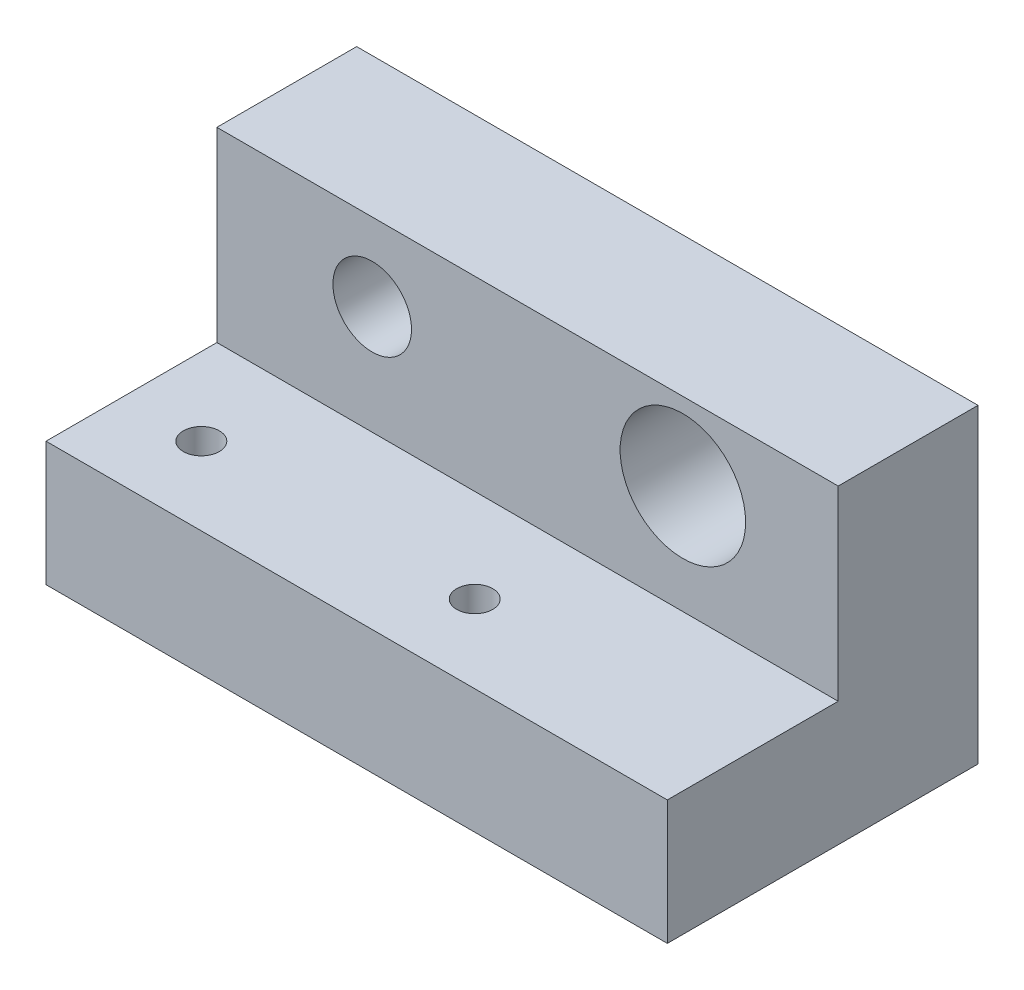
from build123d import *

# Parameters (mm, degrees)
BOSS_EXTRUDE1_DEPTH = 50.8
SKETCH4_R           = 1.4732
CUT_EXTRUDE1_DEPTH  = 11.16
SKETCH5_R           = 3.2131
SKETCH5_R_2         = 5.1308
CUT_EXTRUDE2_DEPTH  = 50.8


with BuildPart() as part:
    # Sketch3 → Boss-Extrude1 (new body)
    with BuildSketch(Plane(origin=(0, 0, 0), x_dir=(0, 0, -1), z_dir=(1, 0, 0))):
        Polygon((0, 0), (25.4, 0), (25.4, 25.4), (13.97, 25.4), (13.97, 10.16), (0, 10.16), align=None)
    extrude(amount=-BOSS_EXTRUDE1_DEPTH)

    # Sketch4 → Cut-Extrude1 (cut, through all)
    with BuildSketch(Plane(origin=(0, 10.16, 0), x_dir=(1, 0, 0), z_dir=(0, 1, 0))):
        with Locations((-44.45, 6.35)):
            Circle(SKETCH4_R)
        with Locations((-22.098, 6.35)):
            Circle(SKETCH4_R)
    extrude(amount=-CUT_EXTRUDE1_DEPTH, mode=Mode.SUBTRACT)

    # Sketch5 → Cut-Extrude2 (cut)
    with BuildSketch(Plane.XY.offset(-13.97)):
        with Locations((-38.1, 19.05)):
            Circle(SKETCH5_R)
        with Locations((-12.7, 19.05)):
            Circle(SKETCH5_R_2)
    extrude(amount=-CUT_EXTRUDE2_DEPTH, mode=Mode.SUBTRACT)


solid = part.part
